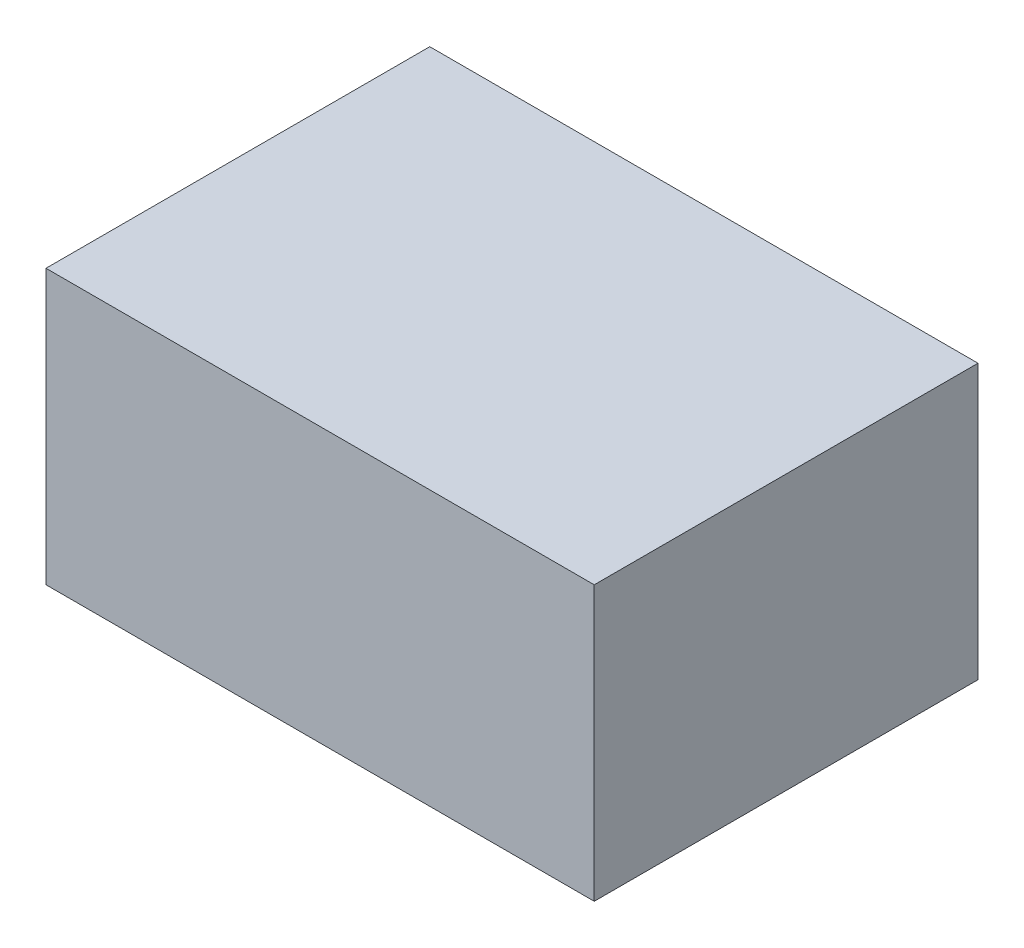
from build123d import *

# Parameters (mm, degrees)
SKETCH2_W           = 100
SKETCH2_H           = 70
BOSS_EXTRUDE1_DEPTH = 50


with BuildPart() as part:
    # Sketch2 → Boss-Extrude1 (new body)
    with BuildSketch(Plane(origin=(0, 0, 0), x_dir=(1, 0, 0), z_dir=(0, 1, 0))):
        Rectangle(SKETCH2_W, SKETCH2_H)
    extrude(amount=BOSS_EXTRUDE1_DEPTH)


solid = part.part
